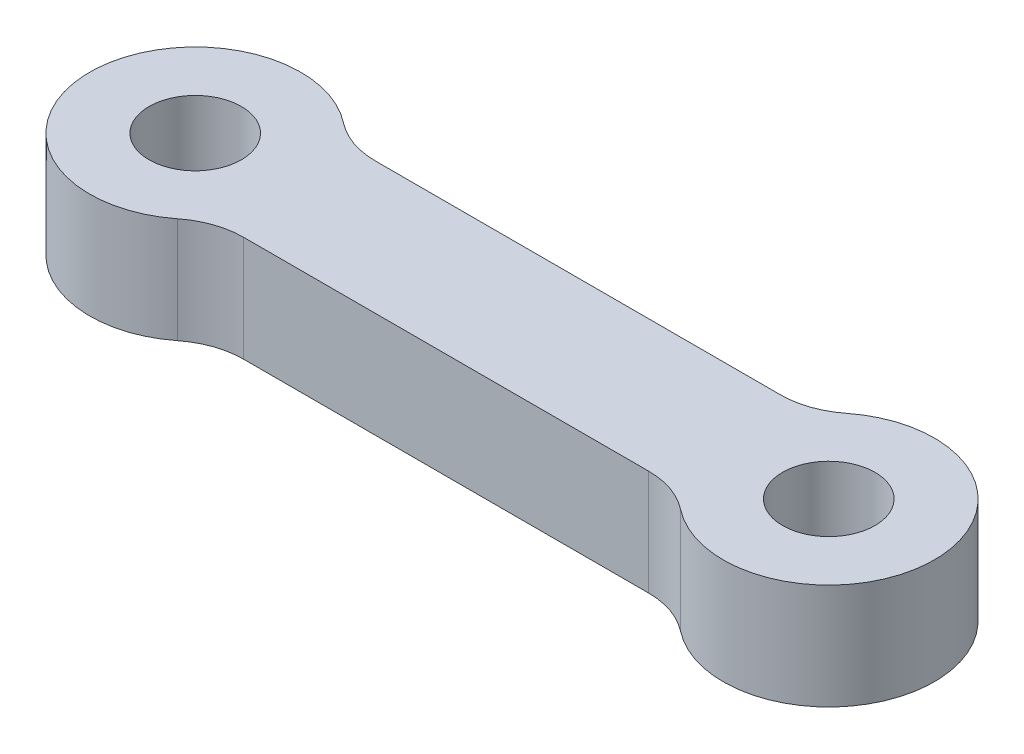
from build123d import *

# Parameters (mm, degrees)
SKETCH1_R           = 1.75
BOSS_EXTRUDE1_DEPTH = 4
FILLET1_R           = 3


with BuildPart() as part:
    # Sketch1 → Boss-Extrude1 (new body)
    with BuildSketch(Plane(origin=(0, 0, 0), x_dir=(1, 0, 0), z_dir=(0, 1, 0))):
        with BuildLine():
            Line((20.877501001, 2.5), (3.122498999, 2.5))
            ThreePointArc((3.122498999, 2.5), (-4, 0), (3.122498999, -2.5))
            Line((3.122498999, -2.5), (20.877501001, -2.5))
            ThreePointArc((20.877501001, -2.5), (28, 0), (20.877501001, 2.5))
        make_face()
        Circle(SKETCH1_R, mode=Mode.SUBTRACT)
        with Locations((24, 0)):
            Circle(SKETCH1_R, mode=Mode.SUBTRACT)
    extrude(amount=BOSS_EXTRUDE1_DEPTH)

    # Fillet1
    fillet1_edges = [part.edges().sort_by_distance(p)[0] for p in [
        (20.877501001, 2, 2.5),
        (3.122498999, 2, 2.5),
        (3.122498999, 2, -2.5),
        (20.877501001, 2, -2.5),
    ]]
    fillet(fillet1_edges, radius=FILLET1_R)


solid = part.part
